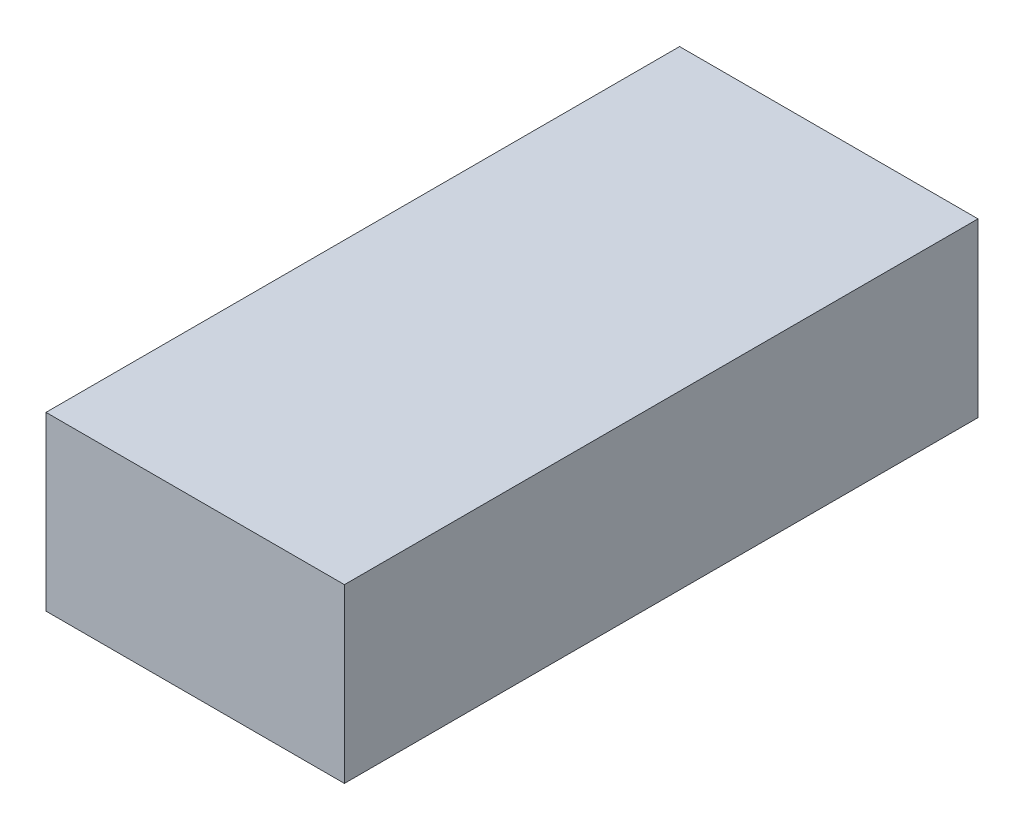
from build123d import *

# Parameters (mm, degrees)
SKETCH1_W           = 33.02
SKETCH1_H           = 70.104
BOSS_EXTRUDE1_DEPTH = 19.05


with BuildPart() as part:
    # Sketch1 → Boss-Extrude1 (new body)
    with BuildSketch(Plane(origin=(0, 0, 0), x_dir=(1, 0, 0), z_dir=(0, 1, 0))):
        with Locations((16.51, 35.052)):
            Rectangle(SKETCH1_W, SKETCH1_H)
    extrude(amount=BOSS_EXTRUDE1_DEPTH)


solid = part.part
